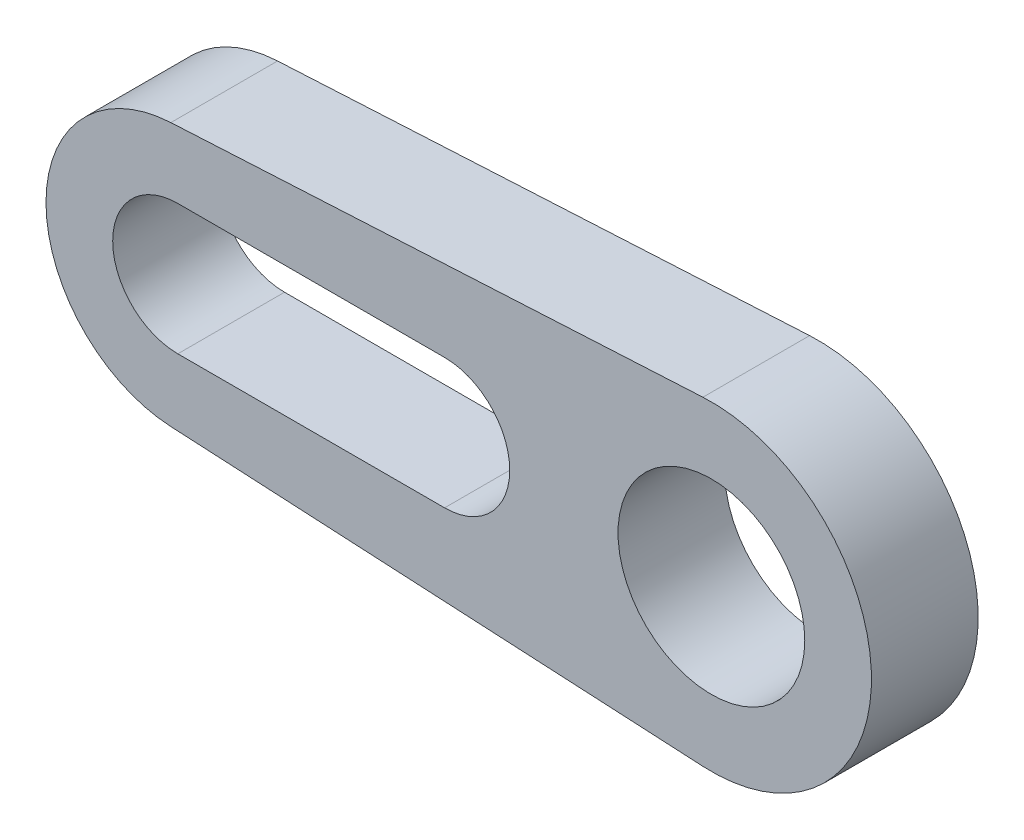
from build123d import *

# Parameters (mm, degrees)
SKETCH1_R           = 2.2225
BOSS_EXTRUDE1_DEPTH = 2.54


with BuildPart() as part:
    # Sketch1 → Boss-Extrude1 (new body)
    with BuildSketch(Plane.XY):
        with BuildLine():
            ThreePointArc((-12.866139272, 3.133098146), (-15.8375, 0), (-12.866139272, -3.133098146))
            Line((-12.866139272, -3.133098146), (-0.20175, -3.804654641))
            ThreePointArc((-0.20175, -3.804654641), (3.81, 0), (-0.20175, 3.804654641))
            Line((-0.20175, 3.804654641), (-12.866139272, 3.133098146))
        make_face()
        with BuildLine():
            Line((-12.7, 1.55), (-6.35, 1.55))
            ThreePointArc((-6.35, 1.55), (-4.8, 0), (-6.35, -1.55))
            Line((-6.35, -1.55), (-12.7, -1.55))
            ThreePointArc((-12.7, -1.55), (-14.25, 0), (-12.7, 1.55))
        make_face(mode=Mode.SUBTRACT)
        Circle(SKETCH1_R, mode=Mode.SUBTRACT)
    extrude(amount=BOSS_EXTRUDE1_DEPTH)


solid = part.part
